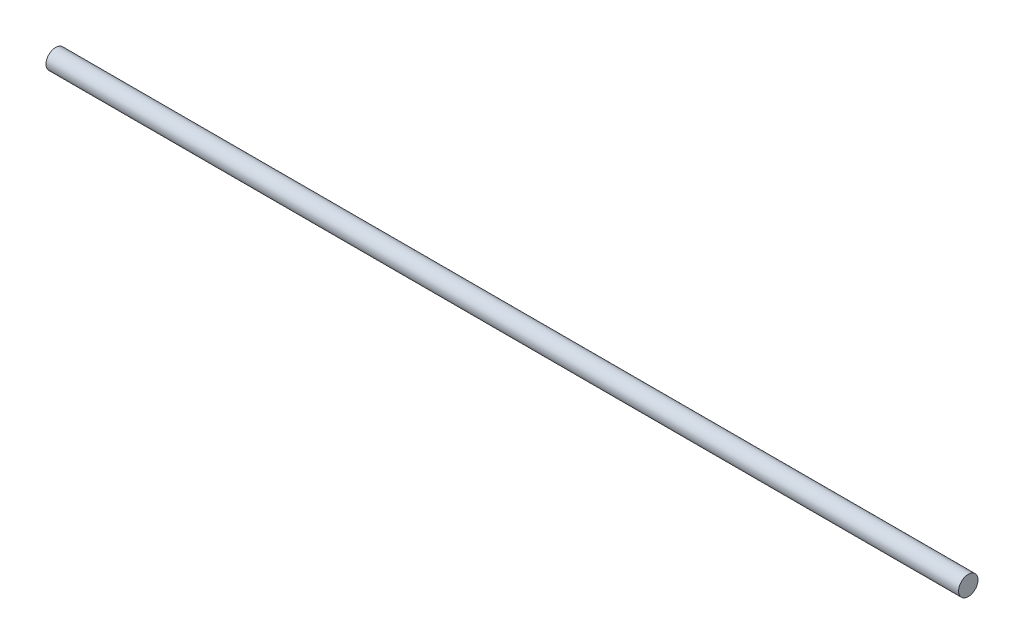
from build123d import *

# Parameters (mm, degrees)
BOSS_EXTRUDE1_DEPTH      = 149.225
BOSS_EXTRUDE1_DEPTH_BACK = 149.225
SKETCH1_R                = 3.175


with BuildPart() as part:
    # Sketch1 → Boss-Extrude1 (new, two sides: drawn at the far end of the back side and taken through both)
    with BuildSketch(Plane(origin=(0, 0, 0), x_dir=(0, 0, -1), z_dir=(1, 0, 0)).offset(-BOSS_EXTRUDE1_DEPTH_BACK)):
        Circle(SKETCH1_R)
    extrude(amount=BOSS_EXTRUDE1_DEPTH + BOSS_EXTRUDE1_DEPTH_BACK)


solid = part.part
